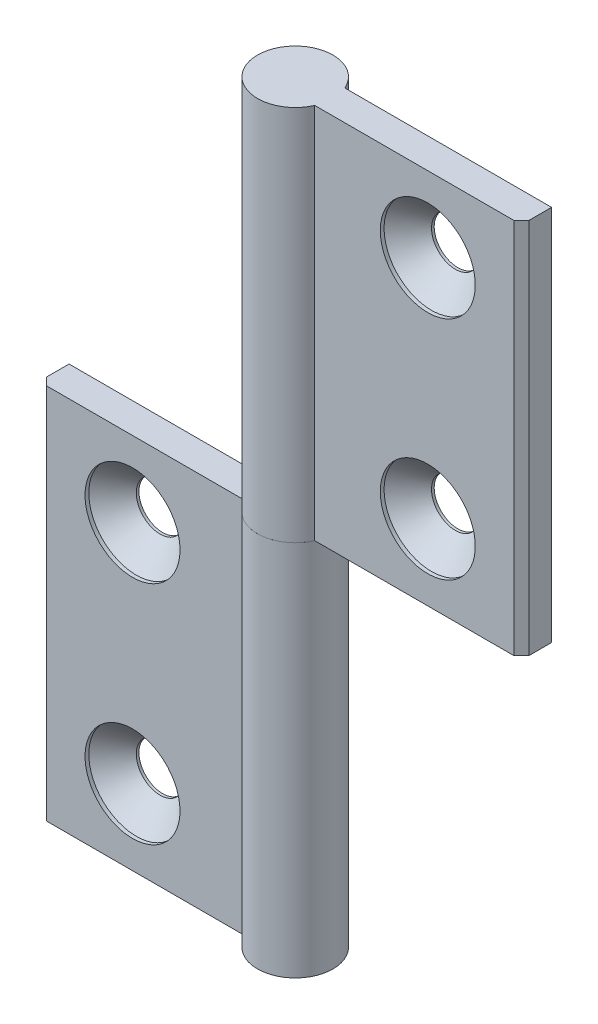
from build123d import *

# Parameters (mm, degrees)
EXTRUDE_1_DEPTH            = 25
HOLE_WIZARD_M61_AT_2_COUNT = 2
HOLE_WIZARD_M61_AT_2_PITCH = 30
PATTERN_CIRCULAR_1_COUNT   = 2


with BuildPart() as part:
    # Эскиз1 → Бобышка-Вытянуть1 (new body, symmetric)
    with BuildSketch(Plane(origin=(0, 0, 0), x_dir=(1, 0, 0), z_dir=(0, 1, 0))):
        with BuildLine():
            Line((-4.582575695, 2), (-32, 2))
            Line((-32, 2), (-32, -1))
            Line((-32, -1), (-31, -2))
            Line((-31, -2), (-4.582575695, -2))
            ThreePointArc((-4.582575695, -2), (5, 0), (-4.582575695, 2))
        make_face()
    extrude(amount=EXTRUDE_1_DEPTH, both=True)

    # Эскиз6 → Зенковка для винта с полупотайной головкой M61 (revolve, cut)
    with BuildSketch(Plane(origin=(-19.582575695, 15, 2), x_dir=(0, -1, 0), z_dir=(1, 0, 0))):
        Polygon((0, 0), (0, 7), (3.15, 7), (3.15, 3.65), (6.3, 0.5), (6.3, 0), align=None)
    hole_wizard_m61 = revolve(axis=Axis((-19.582575695, 15, 8.35), (0, 0, -1)), mode=Mode.SUBTRACT)

    # Зенковка для винта с полупотайной головкой M61 at 2: Зенковка для винта с полупотайной головкой M61 ×2
    with Locations(*[(0, -i * HOLE_WIZARD_M61_AT_2_PITCH, 0) for i in range(1, HOLE_WIZARD_M61_AT_2_COUNT)]):
        add(hole_wizard_m61, mode=Mode.SUBTRACT)


with BuildPart() as pattern_circular_1_1:
    # Круговой массив1: pattern copy
    add(part.part.rotate(Axis((0, 25, 0), (0, 0, 1)), 1 * 360 / PATTERN_CIRCULAR_1_COUNT))


solid = Compound([part.part, pattern_circular_1_1.part])
